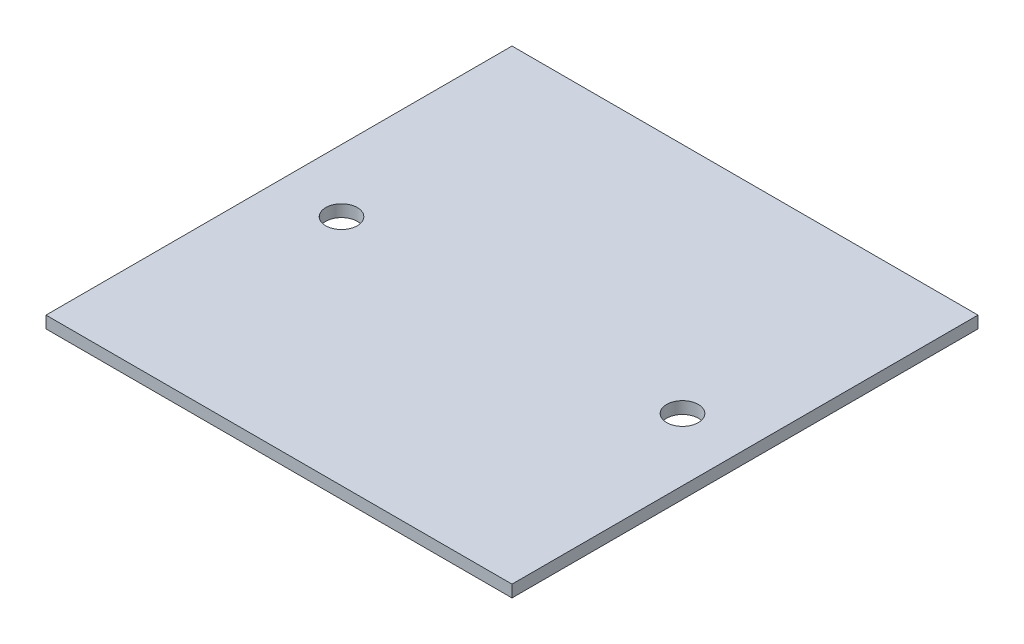
from build123d import *

# Parameters (mm, degrees)
CROQUIS1_W                 = 73.8
CROQUIS1_H                 = 73.8
SALIENTE_EXTRUIR3_DEPTH    = 1.9
CROQUIS2_R                 = 2.5
CORTAR_EXTRUIR1_DEPTH      = 1
CORTAR_EXTRUIR1_DEPTH_BACK = 2.9


with BuildPart() as part:
    # Croquis1 → Saliente-Extruir3 (new body)
    with BuildSketch(Plane(origin=(0, 0, 0), x_dir=(1, 0, 0), z_dir=(0, 1, 0))):
        Rectangle(CROQUIS1_W, CROQUIS1_H)
    extrude(amount=SALIENTE_EXTRUIR3_DEPTH)

    # Croquis2 → Cortar-Extruir1 (cut, two sides)
    with BuildSketch(Plane(origin=(0, 1.9, 0), x_dir=(1, 0, 0), z_dir=(0, 1, 0))) as cortar_extruir1_sk:
        with Locations((-27, 0)):
            Circle(CROQUIS2_R)
        with Locations((27, 0)):
            Circle(CROQUIS2_R)
    extrude(amount=CORTAR_EXTRUIR1_DEPTH, mode=Mode.SUBTRACT)
    extrude(cortar_extruir1_sk.sketch, amount=-CORTAR_EXTRUIR1_DEPTH_BACK, mode=Mode.SUBTRACT)


solid = part.part
